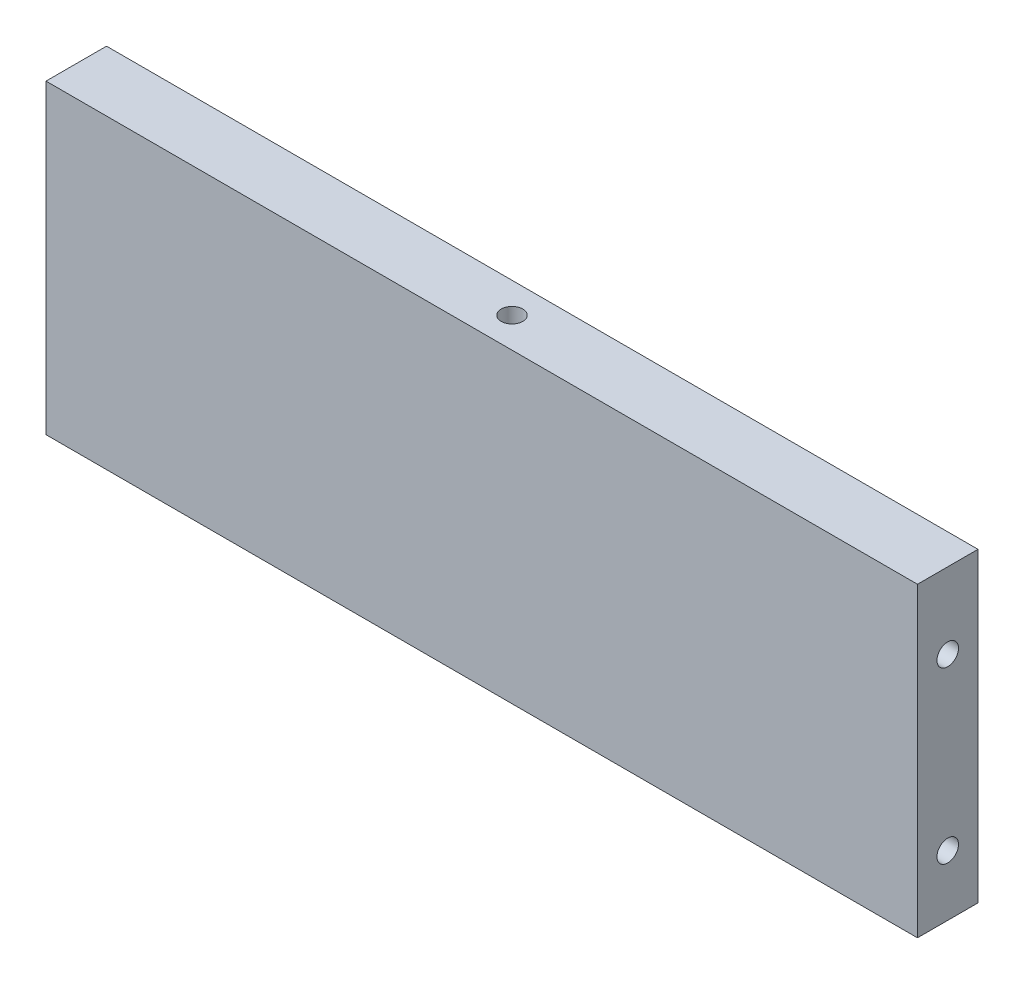
from build123d import *

# Parameters (mm, degrees)
SKETCH1_W           = 91.44
SKETCH1_H           = 6.35
BOSS_EXTRUDE1_DEPTH = 32.131
SKETCH2_R           = 1.1303
CUT_EXTRUDE1_DEPTH  = 12.7
SKETCH3_R           = 1.1303
CUT_EXTRUDE2_DEPTH  = 12.7


with BuildPart() as part:
    # Sketch1 → Boss-Extrude1 (new body)
    with BuildSketch(Plane(origin=(0, 0, 0), x_dir=(1, 0, 0), z_dir=(0, 1, 0))):
        with Locations((-45.72, -3.175)):
            Rectangle(SKETCH1_W, SKETCH1_H)
    extrude(amount=BOSS_EXTRUDE1_DEPTH)

    # Sketch2 → Cut-Extrude1 (cut)
    with BuildSketch(Plane(origin=(0, 0, 0), x_dir=(0, 0, -1), z_dir=(1, 0, 0))):
        with Locations((-3.175, 24.1808)):
            Circle(SKETCH2_R)
        with Locations((-3.175, 6.35)):
            Circle(SKETCH2_R)
    cut_extrude1 = extrude(amount=-CUT_EXTRUDE1_DEPTH, mode=Mode.SUBTRACT)

    # Mirror2: Cut-Extrude1 across plane
    add(cut_extrude1.mirror(Plane(origin=(-45.72, 0, 0), x_dir=(0, 0, 1), z_dir=(1, 0, 0))), mode=Mode.SUBTRACT)

    # Sketch3 → Cut-Extrude2 (cut)
    with BuildSketch(Plane(origin=(0, 32.131, 0), x_dir=(1, 0, 0), z_dir=(0, 1, 0))):
        with Locations((-45.72, -3.175)):
            Circle(SKETCH3_R)
    extrude(amount=-CUT_EXTRUDE2_DEPTH, mode=Mode.SUBTRACT)


solid = part.part
